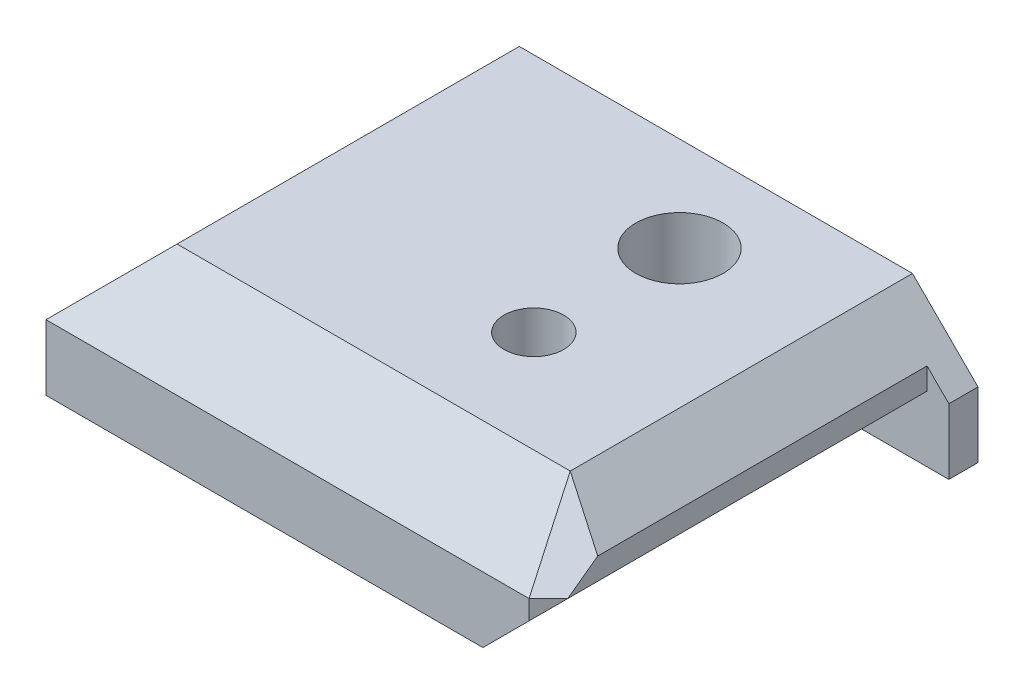
from build123d import *

# Parameters (mm, degrees)
SKETCH1_W               = 36
SKETCH1_H               = 9
BOSS_EXTRUDE1_DEPTH     = 28
CUT_EXTRUDE1_DEPTH      = 28
CUT_EXTRUDE2_DEPTH      = 36
SKETCH5_W               = 11.440376565
SKETCH5_H               = 15.618965423
CUT_EXTRUDE4_DEPTH      = 2
CUT_EXTRUDE5_DEPTH      = 2
CUT_EXTRUDE5_DEPTH_BACK = 2
CUT_EXTRUDE6_DEPTH      = 26
CUT_EXTRUDE7_DEPTH      = 26
SKETCH10_R              = 3
CUT_EXTRUDE8_DEPTH      = 7
SKETCH11_R              = 1.5
CUT_EXTRUDE9_DEPTH      = 2
SKETCH12_R              = 1.5
CUT_EXTRUDE10_DEPTH     = 9
SKETCH13_R              = 2.05
CUT_EXTRUDE11_DEPTH     = 7


with BuildPart() as part:
    # Sketch1 → Boss-Extrude1 (new body)
    with BuildSketch(Plane.XY):
        with Locations((18, 4.5)):
            Rectangle(SKETCH1_W, SKETCH1_H)
    extrude(amount=BOSS_EXTRUDE1_DEPTH)

    # Sketch2 → Cut-Extrude1 (cut)
    with BuildSketch(Plane.XY):
        Polygon((0, 4.5), (4.5, 9), (0, 9), align=None)
        Polygon((36, 4.5), (31.5, 9), (36, 9), align=None)
    extrude(amount=CUT_EXTRUDE1_DEPTH, mode=Mode.SUBTRACT)

    # Sketch3 → Cut-Extrude2 (cut)
    with BuildSketch(Plane(origin=(0, 0, 0), x_dir=(0, 0, -1), z_dir=(1, 0, 0))):
        Polygon((-28, 4.5), (-23.5, 9), (-28, 9), align=None)
    extrude(amount=CUT_EXTRUDE2_DEPTH, mode=Mode.SUBTRACT)

    # Sketch5 → Cut-Extrude4 (cut)
    with BuildSketch(Plane(origin=(32, 0, 32), x_dir=(0, 1, 0), z_dir=(0.707106781, 0, 0.707106781))):
        with Locations((5.720188283, -5.935696583)):
            Rectangle(SKETCH5_W, SKETCH5_H)
    extrude(amount=-CUT_EXTRUDE4_DEPTH, mode=Mode.SUBTRACT)

    # Sketch6 → Cut-Extrude5 (cut, two sides)
    with BuildSketch(Plane(origin=(4, 0, -4), x_dir=(0.577350269, -0.577350269, 0.577350269), z_dir=(-0.707106781, 0, 0.707106781))) as cut_extrude5_sk:
        Polygon((26.558112383, 29.802125204), (32.719347855, 28.647424665), (30.19862658, 32.212262879), align=None)
    extrude(amount=CUT_EXTRUDE5_DEPTH, mode=Mode.SUBTRACT)
    extrude(cut_extrude5_sk.sketch, amount=-CUT_EXTRUDE5_DEPTH_BACK, mode=Mode.SUBTRACT)

    # Sketch7 → Cut-Extrude6 (cut)
    with BuildSketch(Plane.XY):
        Polygon((5, 0), (5, 3), (5.707106781, 3.707106781), (13.104524105, 3.707106781), (13.811630886, 3), (13.811630886, 0), align=None)
    extrude(amount=CUT_EXTRUDE6_DEPTH, mode=Mode.SUBTRACT)

    # Sketch8 → Cut-Extrude7 (cut)
    with BuildSketch(Plane.XY.offset(28)):
        Polygon((36, 0), (30, 0), (34.5, 4.5), (34.5, 6), (36, 6), align=None)
    extrude(amount=-CUT_EXTRUDE7_DEPTH, mode=Mode.SUBTRACT)

    # Sketch10 → Cut-Extrude8 (cut)
    with BuildSketch(Plane(origin=(0, 9, 0), x_dir=(1, 0, 0), z_dir=(0, 1, 0))):
        with Locations((22, -6.5)):
            Circle(SKETCH10_R)
    extrude(amount=-CUT_EXTRUDE8_DEPTH, mode=Mode.SUBTRACT)

    # Sketch11 → Cut-Extrude9 (cut)
    with BuildSketch(Plane(origin=(0, 2, 0), x_dir=(1, 0, 0), z_dir=(0, 1, 0))):
        with Locations((22, -6.5)):
            Circle(SKETCH11_R)
    extrude(amount=-CUT_EXTRUDE9_DEPTH, mode=Mode.SUBTRACT)

    # Sketch12 → Cut-Extrude10 (cut)
    with BuildSketch(Plane(origin=(0, 0, 0), x_dir=(1, 0, 0), z_dir=(0, 1, 0))):
        with Locations((22, -16.5)):
            Circle(SKETCH12_R)
    extrude(amount=CUT_EXTRUDE10_DEPTH, mode=Mode.SUBTRACT)

    # Sketch13 → Cut-Extrude11 (cut)
    with BuildSketch(Plane(origin=(0, 9, 0), x_dir=(1, 0, 0), z_dir=(0, 1, 0))):
        with Locations((22, -16.5)):
            Circle(SKETCH13_R)
    extrude(amount=-CUT_EXTRUDE11_DEPTH, mode=Mode.SUBTRACT)


solid = part.part
